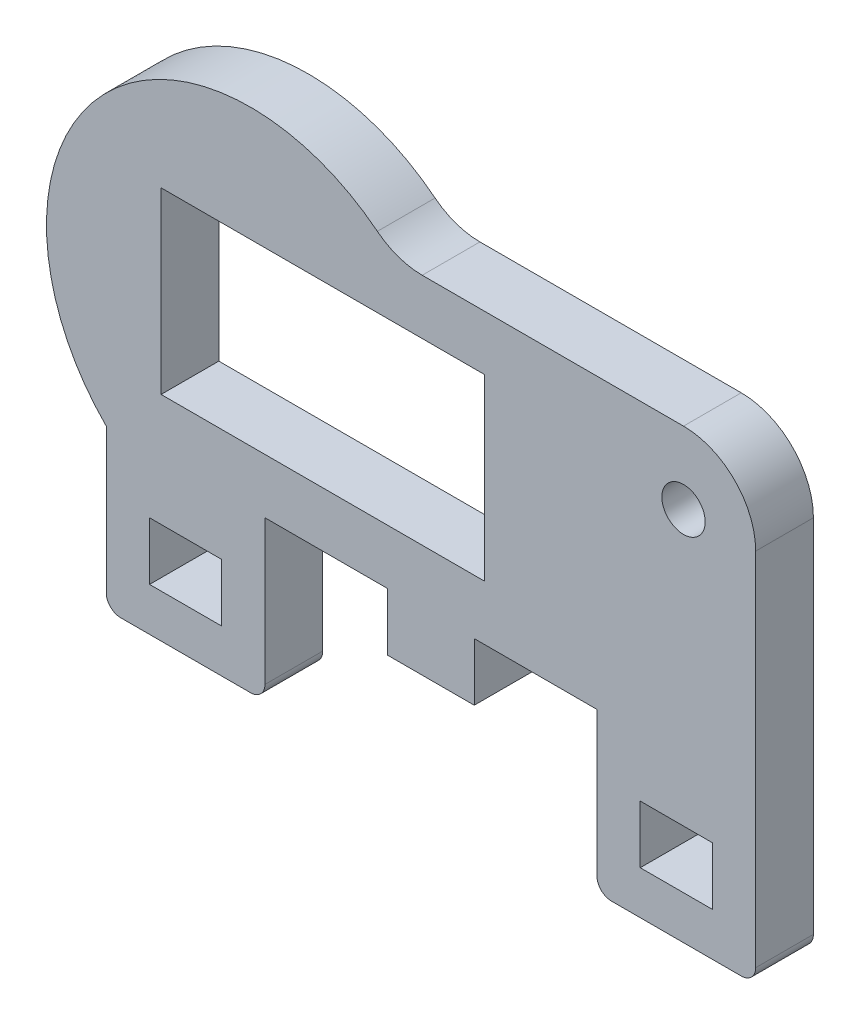
from build123d import *

# Parameters (mm, degrees)
SKETCH1_W           = 22.42
SKETCH1_H           = 12.4
SKETCH1_W_2         = 5
SKETCH1_H_2         = 4
SKETCH1_R           = 1.5
BOSS_EXTRUDE2_DEPTH = 4
FILLET2_R           = 1
FILLET1_R           = 5


with BuildPart() as part:
    # Sketch1 → Boss-Extrude2 (new body)
    with BuildSketch(Plane.XY):
        with BuildLine():
            Line((0, 0), (0, -11))
            Line((0, -11), (11, -11))
            Line((11, -11), (11, 0))
            Line((11, 0), (19.5, 0))
            Line((19.5, 0), (19.5, -4))
            Line((19.5, -4), (25.5, -4))
            Line((25.5, -4), (25.5, 0))
            Line((25.5, 0), (34, 0))
            Line((34, 0), (34, -11))
            Line((34, -11), (45, -11))
            Line((45, -11), (45, 20))
            Line((45, 20), (20, 20))
            ThreePointArc((20, 20), (0, 20), (0, 0))
        make_face()
        with Locations((15.01, 10)):
            Rectangle(SKETCH1_W, SKETCH1_H, mode=Mode.SUBTRACT)
        with Locations((5.5, -6)):
            Rectangle(SKETCH1_W_2, SKETCH1_H_2, mode=Mode.SUBTRACT)
        with Locations((40, 15)):
            Circle(SKETCH1_R, mode=Mode.SUBTRACT)
        with Locations((39.5, -6)):
            Rectangle(SKETCH1_W_2, SKETCH1_H_2, mode=Mode.SUBTRACT)
    extrude(amount=BOSS_EXTRUDE2_DEPTH)

    # Fillet2
    fillet2_edges = [part.edges().sort_by_distance(p)[0] for p in [
        (45, -11, 2),
        (34, -11, 2),
        (11, -11, 2),
        (0, -11, 2),
    ]]
    fillet(fillet2_edges, radius=FILLET2_R)

    # Fillet1
    fillet1_edges = [part.edges().sort_by_distance(p)[0] for p in [
        (45, 20, 2),
        (20, 20, 2),
    ]]
    fillet(fillet1_edges, radius=FILLET1_R)


solid = part.part
